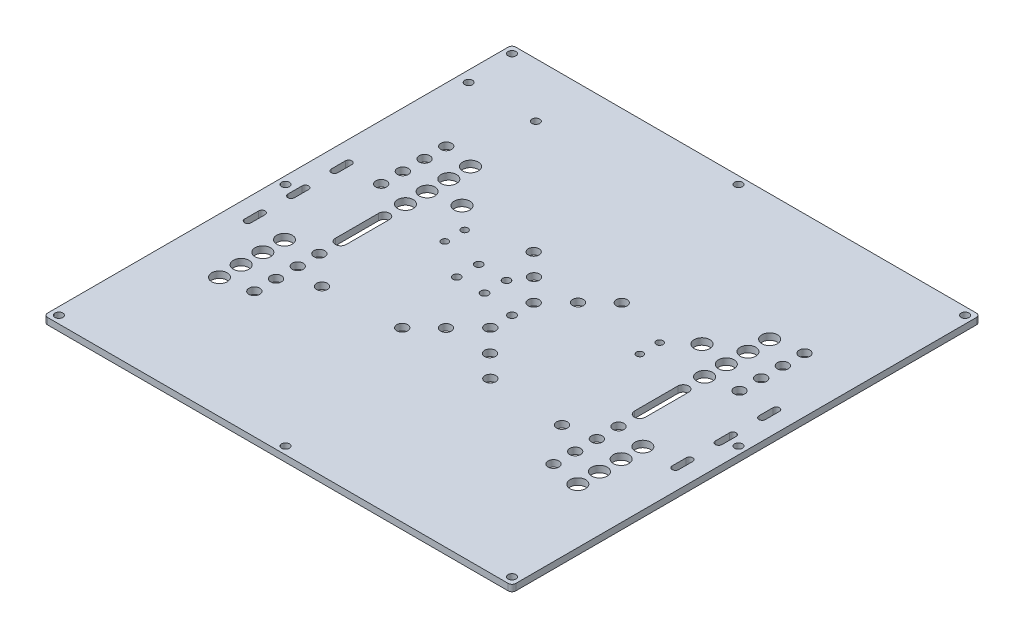
from build123d import *

# Parameters (mm, degrees)
SKETCH1_R           = 1.8
SKETCH1_R_2         = 2.5
SKETCH1_R_3         = 1.57
SKETCH1_R_4         = 1.75
SKETCH1_R_5         = 3.6
BOSS_EXTRUDE1_DEPTH = 3


with BuildPart() as part:
    # Sketch1 → Boss-Extrude1 (new body)
    with BuildSketch(Plane(origin=(0, 0, 0), x_dir=(1, 0, 0), z_dir=(0, 1, 0))):
        with BuildLine():
            Line((106.25, -108), (-106.25, -108))
            ThreePointArc((-106.25, -108), (-107.487436867, -107.487436867), (-108, -106.25))
            Line((-108, -106.25), (-108, 106.25))
            ThreePointArc((-108, 106.25), (-107.487436867, 107.487436867), (-106.25, 108))
            Line((-106.25, 108), (106.25, 108))
            ThreePointArc((106.25, 108), (107.487436867, 107.487436867), (108, 106.25))
            Line((108, 106.25), (108, -106.25))
            ThreePointArc((108, -106.25), (107.487436867, -107.487436867), (106.25, -108))
        make_face()
        with Locations((0, 104.5)):
            Circle(SKETCH1_R, mode=Mode.SUBTRACT)
        with Locations((-104.5, 104.5)):
            Circle(SKETCH1_R, mode=Mode.SUBTRACT)
        with Locations((104.5, 104.5)):
            Circle(SKETCH1_R, mode=Mode.SUBTRACT)
        with Locations((104.5, -104.5)):
            Circle(SKETCH1_R, mode=Mode.SUBTRACT)
        with Locations((0, -104.5)):
            Circle(SKETCH1_R, mode=Mode.SUBTRACT)
        with Locations((-104.5, -104.5)):
            Circle(SKETCH1_R, mode=Mode.SUBTRACT)
        with Locations((104.5, 0)):
            Circle(SKETCH1_R, mode=Mode.SUBTRACT)
        with Locations((-104.5, 0)):
            Circle(SKETCH1_R, mode=Mode.SUBTRACT)
        Circle(SKETCH1_R, mode=Mode.SUBTRACT)
        with Locations((0, 10)):
            Circle(SKETCH1_R_2, mode=Mode.SUBTRACT)
        with Locations((-10.16, 20.32)):
            Circle(SKETCH1_R_2, mode=Mode.SUBTRACT)
        with Locations((-20.325, 30.32)):
            Circle(SKETCH1_R_2, mode=Mode.SUBTRACT)
        with Locations((20.325, 30.32)):
            Circle(SKETCH1_R_2, mode=Mode.SUBTRACT)
        with Locations((10.16, 20.32)):
            Circle(SKETCH1_R_2, mode=Mode.SUBTRACT)
        with Locations((-45, 23.12)):
            Circle(SKETCH1_R_3, mode=Mode.SUBTRACT)
        with Locations((-45, 14)):
            Circle(SKETCH1_R_3, mode=Mode.SUBTRACT)
        with Locations((-28, 12.64)):
            Circle(SKETCH1_R_4, mode=Mode.SUBTRACT)
        with Locations((-15.17, 12.64)):
            Circle(SKETCH1_R_4, mode=Mode.SUBTRACT)
        with Locations((-28, 2.5)):
            Circle(SKETCH1_R_4, mode=Mode.SUBTRACT)
        with Locations((-15.17, 2.5)):
            Circle(SKETCH1_R_4, mode=Mode.SUBTRACT)
        with Locations((20.325, -30.32)):
            Circle(SKETCH1_R_2, mode=Mode.SUBTRACT)
        with Locations((0, -10)):
            Circle(SKETCH1_R_2, mode=Mode.SUBTRACT)
        with Locations((10.16, -20.32)):
            Circle(SKETCH1_R_2, mode=Mode.SUBTRACT)
        with Locations((-10.16, -20.32)):
            Circle(SKETCH1_R_2, mode=Mode.SUBTRACT)
        with Locations((-20.325, -30.32)):
            Circle(SKETCH1_R_2, mode=Mode.SUBTRACT)
        with Locations((45, 14)):
            Circle(SKETCH1_R_3, mode=Mode.SUBTRACT)
        with Locations((45, 23.12)):
            Circle(SKETCH1_R_3, mode=Mode.SUBTRACT)
        with Locations((-82.65, -52.3)):
            Circle(SKETCH1_R_5, mode=Mode.SUBTRACT)
        with Locations((-82.65, -42.3)):
            Circle(SKETCH1_R_5, mode=Mode.SUBTRACT)
        with Locations((-82.65, -32.3)):
            Circle(SKETCH1_R_5, mode=Mode.SUBTRACT)
        with Locations((-82.65, -22.3)):
            Circle(SKETCH1_R_5, mode=Mode.SUBTRACT)
        with Locations((-82.65, 52.3)):
            Circle(SKETCH1_R_2, mode=Mode.SUBTRACT)
        with Locations((-82.65, 42.3)):
            Circle(SKETCH1_R_2, mode=Mode.SUBTRACT)
        with Locations((-82.65, 32.3)):
            Circle(SKETCH1_R_2, mode=Mode.SUBTRACT)
        with Locations((-82.65, 22.3)):
            Circle(SKETCH1_R_2, mode=Mode.SUBTRACT)
        with Locations((82.65, -42.3)):
            Circle(SKETCH1_R_5, mode=Mode.SUBTRACT)
        with Locations((82.65, -32.3)):
            Circle(SKETCH1_R_5, mode=Mode.SUBTRACT)
        with Locations((82.65, -22.3)):
            Circle(SKETCH1_R_5, mode=Mode.SUBTRACT)
        with Locations((82.65, 42.3)):
            Circle(SKETCH1_R_2, mode=Mode.SUBTRACT)
        with Locations((82.65, 32.3)):
            Circle(SKETCH1_R_2, mode=Mode.SUBTRACT)
        with Locations((82.65, 22.3)):
            Circle(SKETCH1_R_2, mode=Mode.SUBTRACT)
        with Locations((82.65, 52.3)):
            Circle(SKETCH1_R_2, mode=Mode.SUBTRACT)
        with Locations((82.65, -52.3)):
            Circle(SKETCH1_R_5, mode=Mode.SUBTRACT)
        with Locations((69, 49.85)):
            Circle(SKETCH1_R_5, mode=Mode.SUBTRACT)
        with Locations((69, -49.85)):
            Circle(SKETCH1_R_2, mode=Mode.SUBTRACT)
        with Locations((69, 39.85)):
            Circle(SKETCH1_R_5, mode=Mode.SUBTRACT)
        with Locations((69, 29.85)):
            Circle(SKETCH1_R_5, mode=Mode.SUBTRACT)
        with Locations((69, 19.85)):
            Circle(SKETCH1_R_5, mode=Mode.SUBTRACT)
        with Locations((69, -39.85)):
            Circle(SKETCH1_R_2, mode=Mode.SUBTRACT)
        with Locations((69, -29.85)):
            Circle(SKETCH1_R_2, mode=Mode.SUBTRACT)
        with Locations((69, -19.85)):
            Circle(SKETCH1_R_2, mode=Mode.SUBTRACT)
        with Locations((-69, 19.85)):
            Circle(SKETCH1_R_5, mode=Mode.SUBTRACT)
        with Locations((-69, 29.85)):
            Circle(SKETCH1_R_5, mode=Mode.SUBTRACT)
        with Locations((-69, 39.85)):
            Circle(SKETCH1_R_5, mode=Mode.SUBTRACT)
        with Locations((-69, -19.85)):
            Circle(SKETCH1_R_2, mode=Mode.SUBTRACT)
        with Locations((-69, -29.85)):
            Circle(SKETCH1_R_2, mode=Mode.SUBTRACT)
        with Locations((-69, -49.85)):
            Circle(SKETCH1_R_2, mode=Mode.SUBTRACT)
        with Locations((-69, 49.85)):
            Circle(SKETCH1_R_5, mode=Mode.SUBTRACT)
        with Locations((-69, -39.85)):
            Circle(SKETCH1_R_2, mode=Mode.SUBTRACT)
        with Locations((-55.35, 32.3)):
            Circle(SKETCH1_R_5, mode=Mode.SUBTRACT)
        with Locations((-55.35, -32.3)):
            Circle(SKETCH1_R_2, mode=Mode.SUBTRACT)
        with Locations((55.35, -32.3)):
            Circle(SKETCH1_R_2, mode=Mode.SUBTRACT)
        with Locations((55.35, 32.3)):
            Circle(SKETCH1_R_5, mode=Mode.SUBTRACT)
        with Locations((-103, 83)):
            Circle(SKETCH1_R, mode=Mode.SUBTRACT)
        with Locations((-72, 83)):
            Circle(SKETCH1_R, mode=Mode.SUBTRACT)
        with BuildLine():
            Line((66.5, -10), (66.5, 10))
            ThreePointArc((66.5, 10), (69, 12.5), (71.5, 10))
            Line((71.5, 10), (71.5, -10))
            ThreePointArc((71.5, -10), (69, -12.5), (66.5, -10))
        make_face(mode=Mode.SUBTRACT)
        with BuildLine():
            Line((97.12, -3.25), (97.12, 3.25))
            ThreePointArc((97.12, 3.25), (98.62, 4.75), (100.12, 3.25))
            Line((100.12, 3.25), (100.12, -3.25))
            ThreePointArc((100.12, -3.25), (98.62, -4.75), (97.12, -3.25))
        make_face(mode=Mode.SUBTRACT)
        with BuildLine():
            Line((97.12, 16.75), (97.12, 23.25))
            ThreePointArc((97.12, 23.25), (98.62, 24.75), (100.12, 23.25))
            Line((100.12, 23.25), (100.12, 16.75))
            ThreePointArc((100.12, 16.75), (98.62, 15.25), (97.12, 16.75))
        make_face(mode=Mode.SUBTRACT)
        with BuildLine():
            Line((97.12, -16.75), (97.12, -23.25))
            ThreePointArc((97.12, -23.25), (98.62, -24.75), (100.12, -23.25))
            Line((100.12, -23.25), (100.12, -16.75))
            ThreePointArc((100.12, -16.75), (98.62, -15.25), (97.12, -16.75))
        make_face(mode=Mode.SUBTRACT)
        with BuildLine():
            Line((-97.12, -16.75), (-97.12, -23.25))
            ThreePointArc((-97.12, -23.25), (-98.62, -24.75), (-100.12, -23.25))
            Line((-100.12, -23.25), (-100.12, -16.75))
            ThreePointArc((-100.12, -16.75), (-98.62, -15.25), (-97.12, -16.75))
        make_face(mode=Mode.SUBTRACT)
        with BuildLine():
            Line((-97.12, -3.25), (-97.12, 3.25))
            ThreePointArc((-97.12, 3.25), (-98.62, 4.75), (-100.12, 3.25))
            Line((-100.12, 3.25), (-100.12, -3.25))
            ThreePointArc((-100.12, -3.25), (-98.62, -4.75), (-97.12, -3.25))
        make_face(mode=Mode.SUBTRACT)
        with BuildLine():
            Line((-97.12, 16.75), (-97.12, 23.25))
            ThreePointArc((-97.12, 23.25), (-98.62, 24.75), (-100.12, 23.25))
            Line((-100.12, 23.25), (-100.12, 16.75))
            ThreePointArc((-100.12, 16.75), (-98.62, 15.25), (-97.12, 16.75))
        make_face(mode=Mode.SUBTRACT)
        with BuildLine():
            Line((-66.5, -10), (-66.5, 10))
            ThreePointArc((-66.5, 10), (-69, 12.5), (-71.5, 10))
            Line((-71.5, 10), (-71.5, -10))
            ThreePointArc((-71.5, -10), (-69, -12.5), (-66.5, -10))
        make_face(mode=Mode.SUBTRACT)
    extrude(amount=BOSS_EXTRUDE1_DEPTH)


solid = part.part
